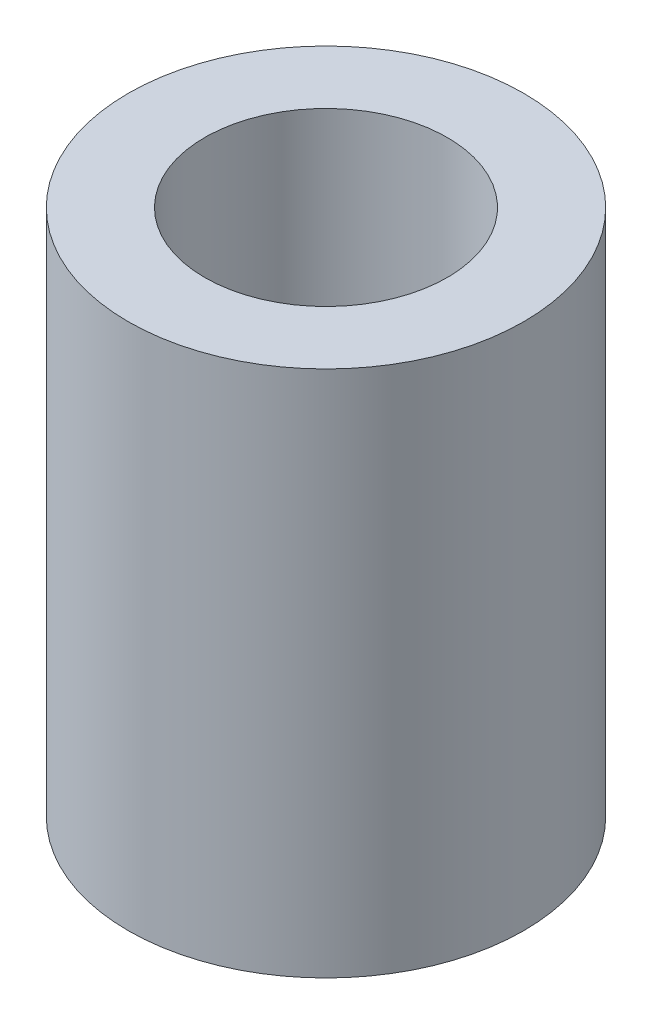
from build123d import *

# Parameters (mm, degrees)
SKETCH1_R           = 2.38125
SKETCH1_R_2         = 1.4605
BOSS_EXTRUDE1_DEPTH = 6.35


with BuildPart() as part:
    # Sketch1 → Boss-Extrude1 (new body)
    with BuildSketch(Plane(origin=(0, 0, 0), x_dir=(1, 0, 0), z_dir=(0, 1, 0))):
        Circle(SKETCH1_R)
        Circle(SKETCH1_R_2, mode=Mode.SUBTRACT)
    extrude(amount=BOSS_EXTRUDE1_DEPTH)


solid = part.part
